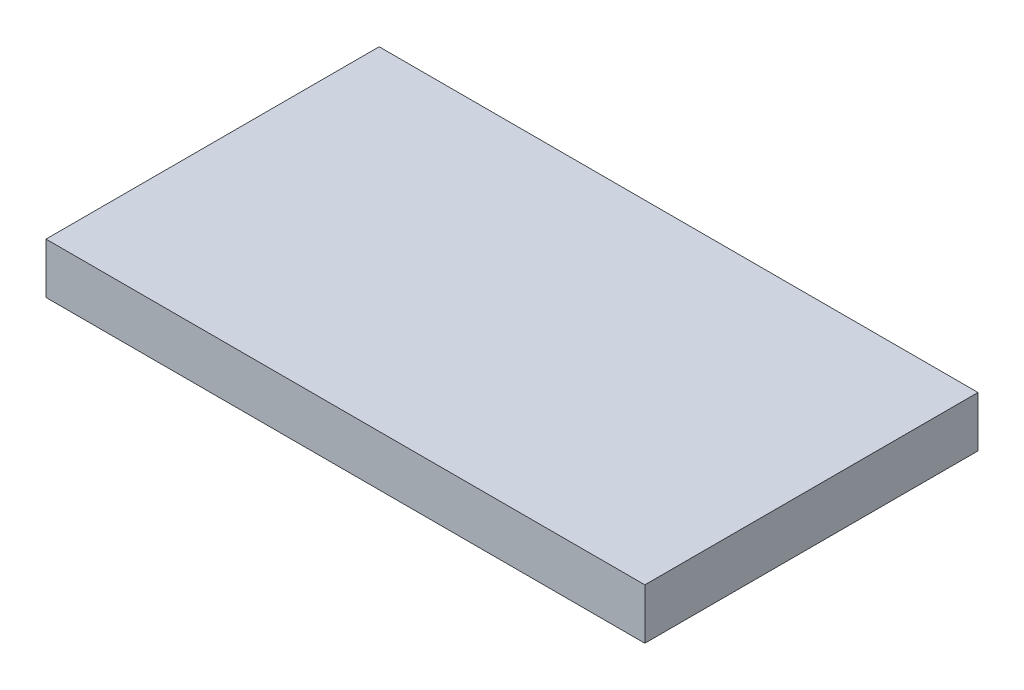
from build123d import *

# Parameters (mm, degrees)
SKETCH1_W           = 18.034
SKETCH1_H           = 10.033
BOSS_EXTRUDE1_DEPTH = 1.524


with BuildPart() as part:
    # Sketch1 → Boss-Extrude1 (new body)
    with BuildSketch(Plane(origin=(0, 0, 0), x_dir=(1, 0, 0), z_dir=(0, 1, 0))):
        with Locations((9.017, 5.0165)):
            Rectangle(SKETCH1_W, SKETCH1_H)
    extrude(amount=BOSS_EXTRUDE1_DEPTH)


solid = part.part
